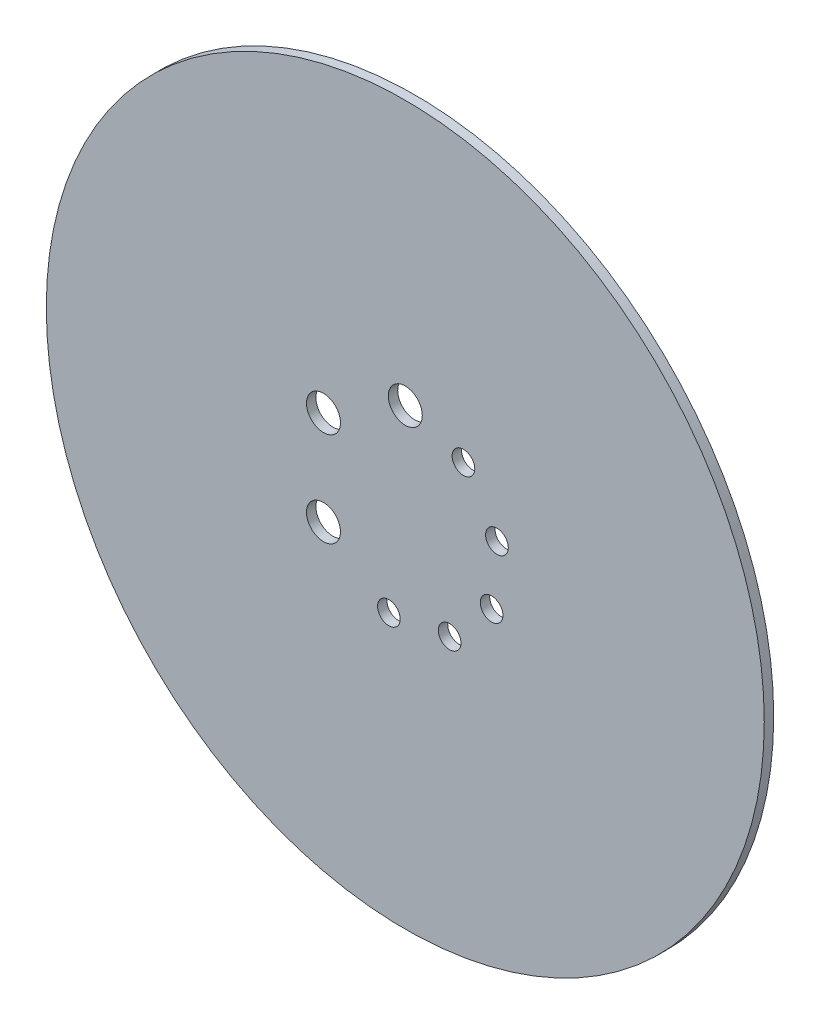
from build123d import *

# Parameters (mm, degrees)
SKETCH1_R           = 190
BOSS_EXTRUDE1_DEPTH = 5
SKETCH2_R           = 9
SKETCH2_R_2         = 6
CUT_EXTRUDE1_DEPTH  = 10


with BuildPart() as part:
    # Sketch1 → Boss-Extrude1 (new body)
    with BuildSketch(Plane.XY):
        Circle(SKETCH1_R)
    extrude(amount=BOSS_EXTRUDE1_DEPTH)

    # Sketch2 → Cut-Extrude1 (cut)
    with BuildSketch(Plane(origin=(0, 0, 0), x_dir=(-1, 0, 0), z_dir=(0, 0, -1))):
        with Locations((0, 50)):
            Circle(SKETCH2_R)
        with Locations((43.301270189, 25)):
            Circle(SKETCH2_R)
        with Locations((43.301270189, -25)):
            Circle(SKETCH2_R)
        with Locations((-30.783073766, 39.40053768)):
            Circle(SKETCH2_R_2)
        with Locations((-48.514786314, 12.09609478)):
            Circle(SKETCH2_R_2)
        with Locations((-45.677272882, -20.336832154)):
            Circle(SKETCH2_R_2)
        with Locations((-23.473578139, -44.147379643)):
            Circle(SKETCH2_R_2)
        with Locations((8.682408883, -49.240387651)):
            Circle(SKETCH2_R_2)
    extrude(amount=-CUT_EXTRUDE1_DEPTH, mode=Mode.SUBTRACT)


solid = part.part
